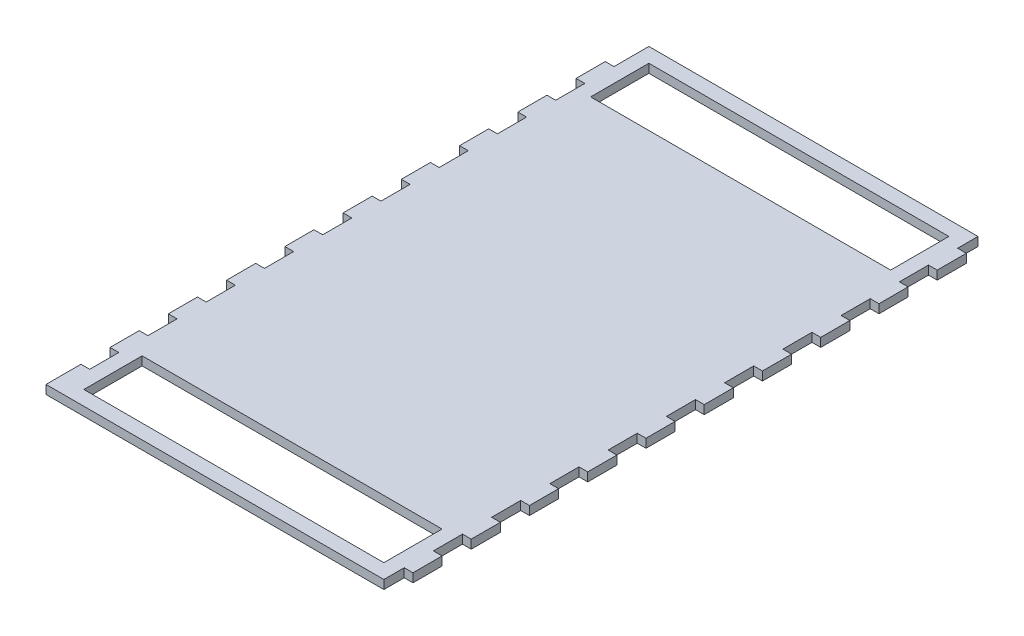
from build123d import *

# Parameters (mm, degrees)
SKETCH1_W           = 113
SKETCH1_H           = 204
BOSS_EXTRUDE1_DEPTH = 3
SKETCH2_W           = 10
SKETCH2_H           = 3
BOSS_EXTRUDE2_DEPTH = 3
LPATTERN1_COUNT     = 10
LPATTERN1_PITCH     = 20
SKETCH4_W           = 103
SKETCH4_H           = 20
CUT_EXTRUDE1_DEPTH  = 4
SKETCH3_W           = 12
SKETCH3_H           = 3
SKETCH3_W_2         = 10
BOSS_EXTRUDE3_DEPTH = 3


with BuildPart() as part:
    # Sketch1 → Boss-Extrude1 (new body)
    with BuildSketch(Plane(origin=(0, 0, 0), x_dir=(1, 0, 0), z_dir=(0, 1, 0))):
        with Locations((56.5, 102)):
            Rectangle(SKETCH1_W, SKETCH1_H)
    extrude(amount=BOSS_EXTRUDE1_DEPTH)

    # Sketch2 → Boss-Extrude2 (add)
    with BuildSketch(Plane(origin=(113, 0, 0), x_dir=(0, 0, -1), z_dir=(1, 0, 0))):
        with Locations((12, 1.5)):
            Rectangle(SKETCH2_W, SKETCH2_H)
    boss_extrude2 = extrude(amount=BOSS_EXTRUDE2_DEPTH)

    # LPattern1: Boss-Extrude2 ×10
    with Locations(*[(0, 0, -i * LPATTERN1_PITCH) for i in range(1, LPATTERN1_COUNT)]):
        add(boss_extrude2)

    # Sketch4 → Cut-Extrude1 (cut, through all)
    with BuildSketch(Plane(origin=(0, 3, 0), x_dir=(1, 0, 0), z_dir=(0, 1, 0))):
        with Locations((56.5, 15)):
            Rectangle(SKETCH4_W, SKETCH4_H)
        with Locations((56.5, 189)):
            Rectangle(SKETCH4_W, SKETCH4_H)
    extrude(amount=-CUT_EXTRUDE1_DEPTH, mode=Mode.SUBTRACT)

    # Sketch3 → Boss-Extrude3 (add)
    with BuildSketch(Plane.ZY):
        with Locations((-6, 1.5)):
            Rectangle(SKETCH3_W, SKETCH3_H)
        with Locations((-27, 1.5)):
            Rectangle(SKETCH3_W_2, SKETCH3_H)
        with Locations((-47, 1.5)):
            Rectangle(SKETCH3_W_2, SKETCH3_H)
        with Locations((-67, 1.5)):
            Rectangle(SKETCH3_W_2, SKETCH3_H)
        with Locations((-87, 1.5)):
            Rectangle(SKETCH3_W_2, SKETCH3_H)
        with Locations((-107, 1.5)):
            Rectangle(SKETCH3_W_2, SKETCH3_H)
        with Locations((-127, 1.5)):
            Rectangle(SKETCH3_W_2, SKETCH3_H)
        with Locations((-147, 1.5)):
            Rectangle(SKETCH3_W_2, SKETCH3_H)
        with Locations((-167, 1.5)):
            Rectangle(SKETCH3_W_2, SKETCH3_H)
        with Locations((-187, 1.5)):
            Rectangle(SKETCH3_W_2, SKETCH3_H)
    extrude(amount=BOSS_EXTRUDE3_DEPTH)


solid = part.part
